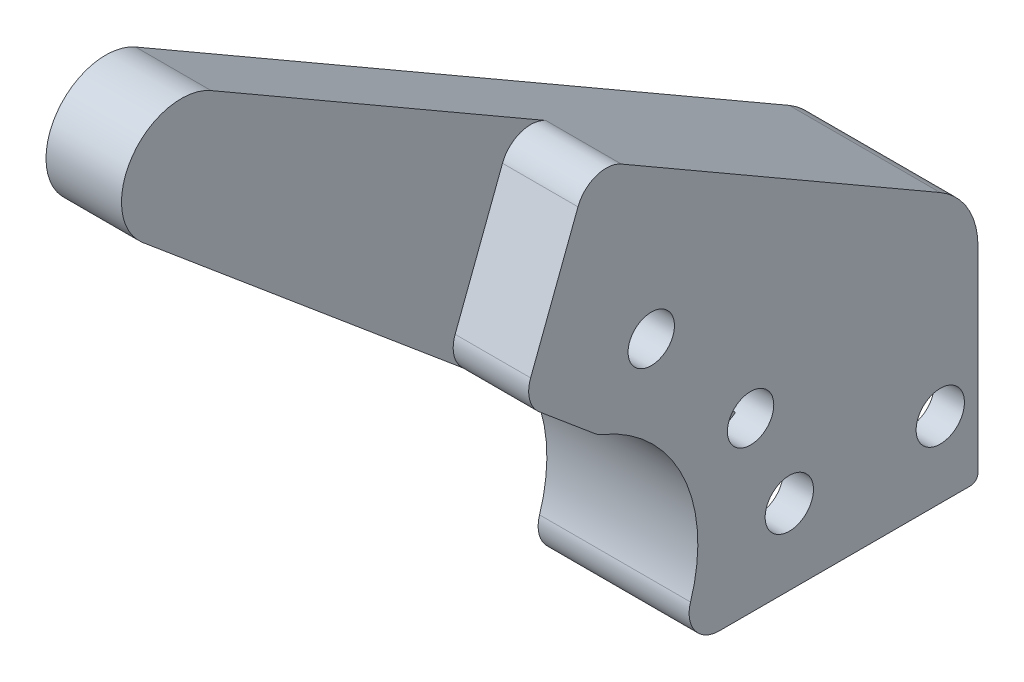
from build123d import *

# Parameters (mm, degrees)
SKETCH1_R           = 2.032
BOSS_EXTRUDE1_DEPTH = 2.54
BOSS_EXTRUDE2_START = -7.62
BOSS_EXTRUDE2_DEPTH = 7.62
BOSS_EXTRUDE3_START = 2.54
SKETCH4_R           = 2.032
BOSS_EXTRUDE3_DEPTH = 2.54
CUT_EXTRUDE2_START  = -6.35
CUT_EXTRUDE2_DEPTH  = 6.35
FILLET1_R           = 2.54
FILLET2_R           = 0.635
SKETCH6_R           = 1.95
CUT_EXTRUDE3_DEPTH  = 74.28469602


with BuildPart() as part:
    # Sketch1 → Boss-Extrude1 (new body)
    with BuildSketch(Plane(origin=(0, 0, 0), x_dir=(0, 0, -1), z_dir=(1, 0, 0))):
        with BuildLine():
            Line((19.05, 0), (19.05, 17.145))
            ThreePointArc((19.05, 17.145), (18.199261314, 20.32), (15.875, 22.644261314))
            Line((15.875, 22.644261314), (-39.11761314, 54.394261314))
            ThreePointArc((-39.11761314, 54.394261314), (-45.74830741, 52.924271785), (-44.861814719, 46.190691279))
            Line((-44.861814719, 46.190691279), (-12.887784973, 19.361294713))
            ThreePointArc((-12.887784973, 19.361294713), (-5.127948142, 11.168903642), (-6.736031019, 0))
            Line((-6.736031019, 0), (19.05, 0))
        make_face()
        with Locations((3.175, 6.35)):
            Circle(SKETCH1_R, mode=Mode.SUBTRACT)
        with Locations((15.875, 6.35)):
            Circle(SKETCH1_R, mode=Mode.SUBTRACT)
    extrude(amount=BOSS_EXTRUDE1_DEPTH)

    # Sketch1_4 → Boss-Extrude2 (add)
    with BuildSketch(Plane(origin=(0, 0, 0), x_dir=(0, 0, -1), z_dir=(1, 0, 0)).offset(BOSS_EXTRUDE2_START)):
        with BuildLine():
            Line((-6.736031019, 0), (0, 0))
            Line((0, 0), (0, 12.7))
            Line((0, 12.7), (19.05, 12.7))
            Line((19.05, 12.7), (19.05, 17.145))
            ThreePointArc((19.05, 17.145), (18.199261314, 20.32), (15.875, 22.644261314))
            Line((15.875, 22.644261314), (-39.11761314, 54.394261314))
            ThreePointArc((-39.11761314, 54.394261314), (-45.74830741, 52.924271785), (-44.861814719, 46.190691279))
            Line((-44.861814719, 46.190691279), (-12.887784973, 19.361294713))
            ThreePointArc((-12.887784973, 19.361294713), (-5.127948142, 11.168903642), (-6.736031019, 0))
        make_face()
    extrude(amount=BOSS_EXTRUDE2_DEPTH)

    # Sketch4 → Boss-Extrude3 (add)
    with BuildSketch(Plane.ZY.offset(7.62).offset(BOSS_EXTRUDE3_START)):
        with BuildLine():
            Line((-19.05, 0), (6.736031019, 0))
            ThreePointArc((6.736031019, 0), (5.127948142, 11.168903642), (12.887784973, 19.361294713))
            Line((12.887784973, 19.361294713), (44.861814719, 46.190691279))
            ThreePointArc((44.861814719, 46.190691279), (45.74830741, 52.924271785), (39.11761314, 54.394261314))
            Line((39.11761314, 54.394261314), (-15.875, 22.644261314))
            ThreePointArc((-15.875, 22.644261314), (-18.199261314, 20.32), (-19.05, 17.145))
            Line((-19.05, 17.145), (-19.05, 0))
        make_face()
        with Locations((-3.175, 6.35)):
            Circle(SKETCH4_R, mode=Mode.SUBTRACT)
        with Locations((-15.875, 6.35)):
            Circle(SKETCH4_R, mode=Mode.SUBTRACT)
    extrude(amount=-BOSS_EXTRUDE3_DEPTH)

    # Sketch5 → Cut-Extrude2 (cut)
    with BuildSketch(Plane(origin=(2.54, 0, 0), x_dir=(0, 0, -1), z_dir=(1, 0, 0)).offset(CUT_EXTRUDE2_START)):
        with BuildLine():
            Line((-19.229074876, 24.682268731), (-13.542236075, 39.628310481))
            Line((-13.542236075, 39.628310481), (-39.11761314, 54.394261314))
            ThreePointArc((-39.11761314, 54.394261314), (-45.74830741, 52.924271785), (-44.861814719, 46.190691279))
            Line((-44.861814719, 46.190691279), (-19.229074876, 24.682268731))
        make_face()
    extrude(amount=CUT_EXTRUDE2_DEPTH, mode=Mode.SUBTRACT)

    # Fillet1
    fillet1_edges = [part.edges().sort_by_distance(p)[0] for p in [
        (-3.81, 0, 6.736031019),
        (-0.635, 39.628310481, 13.542236075),
        (-3.81, 19.361294713, 12.887784973),
        (-0.635, 24.682268731, 19.229074876),
    ]]
    fillet(fillet1_edges, radius=FILLET1_R)

    # Fillet2
    fillet2_edges = [part.edges().sort_by_distance(p)[0] for p in [
        (-3.81, 0, 0),
        (-8.89, 0, -19.05),
        (1.27, 0, -19.05),
        (-3.81, 12.7, -19.05),
    ]]
    fillet(fillet2_edges, radius=FILLET2_R)

    # Sketch6 → Cut-Extrude3 (cut, through all)
    with BuildSketch(Plane(origin=(2.54, 0, 0), x_dir=(0, 0, -1), z_dir=(1, 0, 0))):
        with Locations((-0.082541576, 14.180960145)):
            Circle(SKETCH6_R)
        with Locations((-8.438780502, 24.139537906)):
            Circle(SKETCH6_R)
    extrude(amount=-CUT_EXTRUDE3_DEPTH, mode=Mode.SUBTRACT)


solid = part.part
